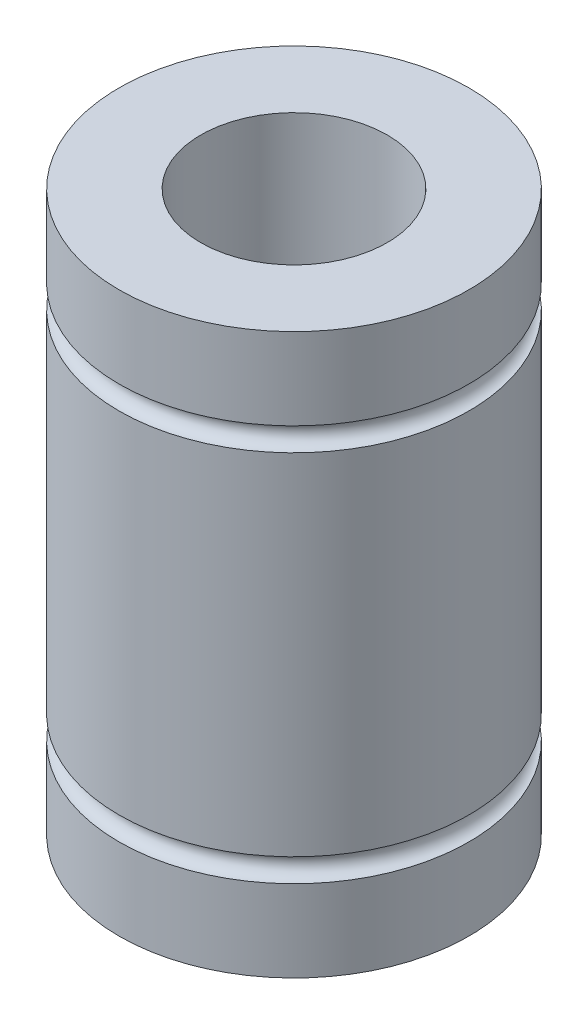
from build123d import *

# Parameters (mm, degrees)
SKETCH1_R           = 7.5
SKETCH1_R_2         = 4
BOSS_EXTRUDE1_DEPTH = 24
SKETCH2_R           = 0.5


with BuildPart() as part:
    # Sketch1 → Boss-Extrude1 (new body)
    with BuildSketch(Plane(origin=(0, 0, 0), x_dir=(1, 0, 0), z_dir=(0, 1, 0))):
        Circle(SKETCH1_R)
        Circle(SKETCH1_R_2, mode=Mode.SUBTRACT)
    extrude(amount=BOSS_EXTRUDE1_DEPTH)

    # Sketch2 → Cut-Revolve1 (revolve, cut)
    with BuildSketch(Plane.XY):
        with Locations((7.5, 4)):
            Circle(SKETCH2_R)
        with Locations((7.5, 20)):
            Circle(SKETCH2_R)
    revolve(axis=Axis((0, 20.782039023, 0), (0, -1, 0)), mode=Mode.SUBTRACT)


solid = part.part
